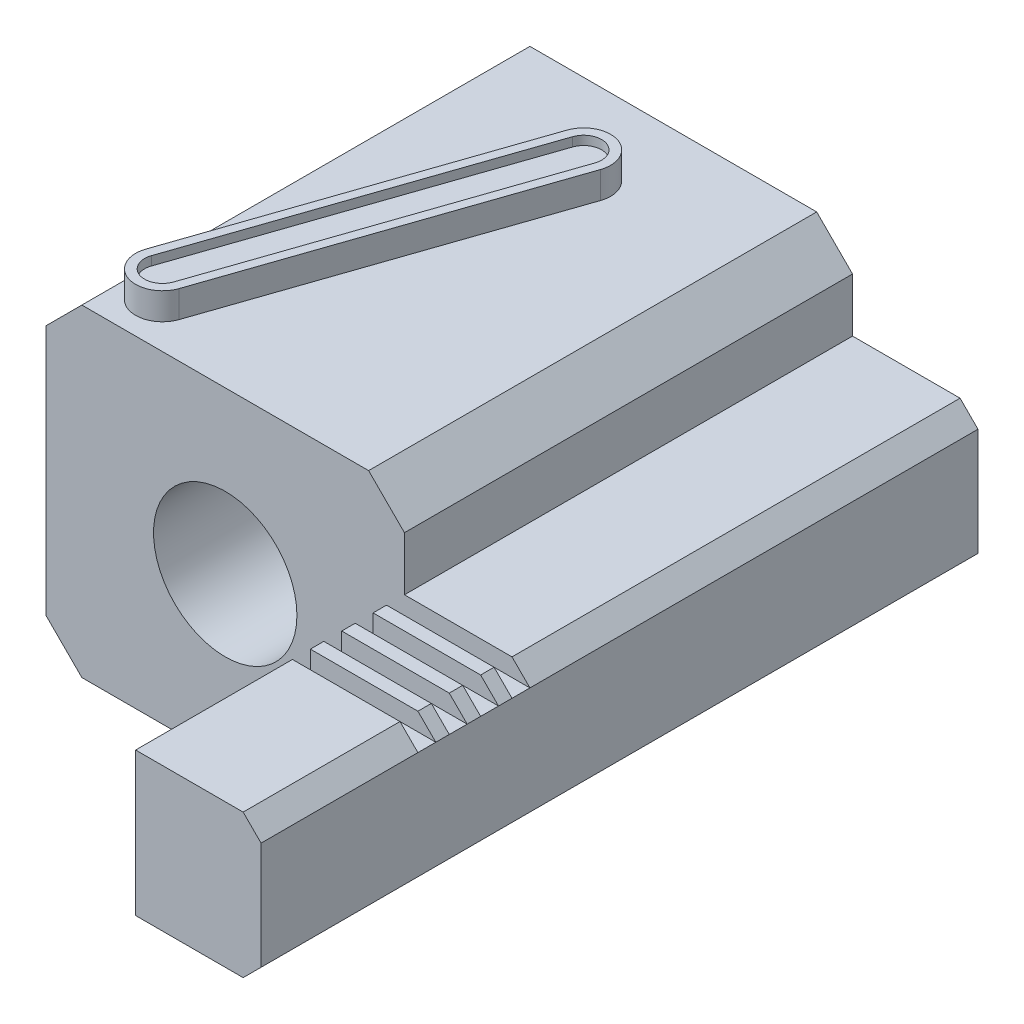
from build123d import *

# Parameters (mm, degrees)
SKETCH1_W           = 20
SKETCH1_H           = 18
BOSS_EXTRUDE1_DEPTH = 25
SKETCH2_R           = 4
CUT_EXTRUDE1_DEPTH  = 26
CHAMFER1_SIZE       = 2
BOSS_EXTRUDE2_DEPTH = 1.5
CUT_EXTRUDE2_DEPTH  = 0.5
BOSS_EXTRUDE3_DEPTH = 40
SKETCH6_W           = 1
SKETCH6_H           = 1
CUT_EXTRUDE3_DEPTH  = 8


with BuildPart() as part:
    # Sketch1 → Boss-Extrude1 (new body)
    with BuildSketch(Plane.XY):
        Rectangle(SKETCH1_W, SKETCH1_H)
    extrude(amount=BOSS_EXTRUDE1_DEPTH)

    # Sketch2 → Cut-Extrude1 (cut, through all)
    with BuildSketch(Plane.XY.offset(25)):
        Circle(SKETCH2_R)
    extrude(amount=-CUT_EXTRUDE1_DEPTH, mode=Mode.SUBTRACT)

    # Chamfer1
    chamfer1_edges = [part.edges().sort_by_distance(p)[0] for p in [
        (10, 9, 12.5),
        (10, -9, 12.5),
        (-10, -9, 12.5),
        (-10, 9, 12.5),
    ]]
    chamfer(chamfer1_edges, length=CHAMFER1_SIZE)

    # Sketch3 → Boss-Extrude2 (add)
    with BuildSketch(Plane(origin=(0, 9, 0), x_dir=(1, 0, 0), z_dir=(0, 1, 0))):
        with BuildLine():
            Line((-7.418918919, -22.013513514), (-1.418918919, -4.513513514))
            ThreePointArc((-1.418918919, -4.513513514), (0.486486486, -3.581081081), (1.418918919, -5.486486486))
            Line((1.418918919, -5.486486486), (-4.581081081, -22.986486486))
            ThreePointArc((-4.581081081, -22.986486486), (-6.486486486, -23.918918919), (-7.418918919, -22.013513514))
        make_face()
    extrude(amount=BOSS_EXTRUDE2_DEPTH)

    # Sketch4 → Cut-Extrude2 (cut)
    with BuildSketch(Plane(origin=(0, 10.5, 0), x_dir=(1, 0, 0), z_dir=(0, 1, 0))):
        with BuildLine():
            Line((-6.945945946, -22.175675676), (-0.945945946, -4.675675676))
            ThreePointArc((-0.945945946, -4.675675676), (0.324324324, -4.054054054), (0.945945946, -5.324324324))
            Line((0.945945946, -5.324324324), (-5.054054054, -22.824324324))
            ThreePointArc((-5.054054054, -22.824324324), (-6.324324324, -23.445945946), (-6.945945946, -22.175675676))
        make_face()
    extrude(amount=-CUT_EXTRUDE2_DEPTH, mode=Mode.SUBTRACT)

    # Sketch5 → Boss-Extrude3 (add)
    with BuildSketch(Plane(origin=(0, 0, 0), x_dir=(-1, 0, 0), z_dir=(0, 0, -1))):
        Polygon((-10, 4), (-16, 4), (-17, 3), (-17, -3), (-16, -4), (-10, -4), align=None)
    extrude(amount=-BOSS_EXTRUDE3_DEPTH)

    # Sketch6 → Cut-Extrude3 (cut, through all)
    with BuildSketch(Plane.ZY.offset(-10)):
        with Locations((25.5, 3.5)):
            Rectangle(SKETCH6_W, SKETCH6_H)
        with Locations((27.25, 3.5)):
            Rectangle(SKETCH6_W, SKETCH6_H)
        with Locations((29, 3.5)):
            Rectangle(SKETCH6_W, SKETCH6_H)
        with Locations((30.75, 3.5)):
            Rectangle(SKETCH6_W, SKETCH6_H)
    extrude(amount=-CUT_EXTRUDE3_DEPTH, mode=Mode.SUBTRACT)


solid = part.part
